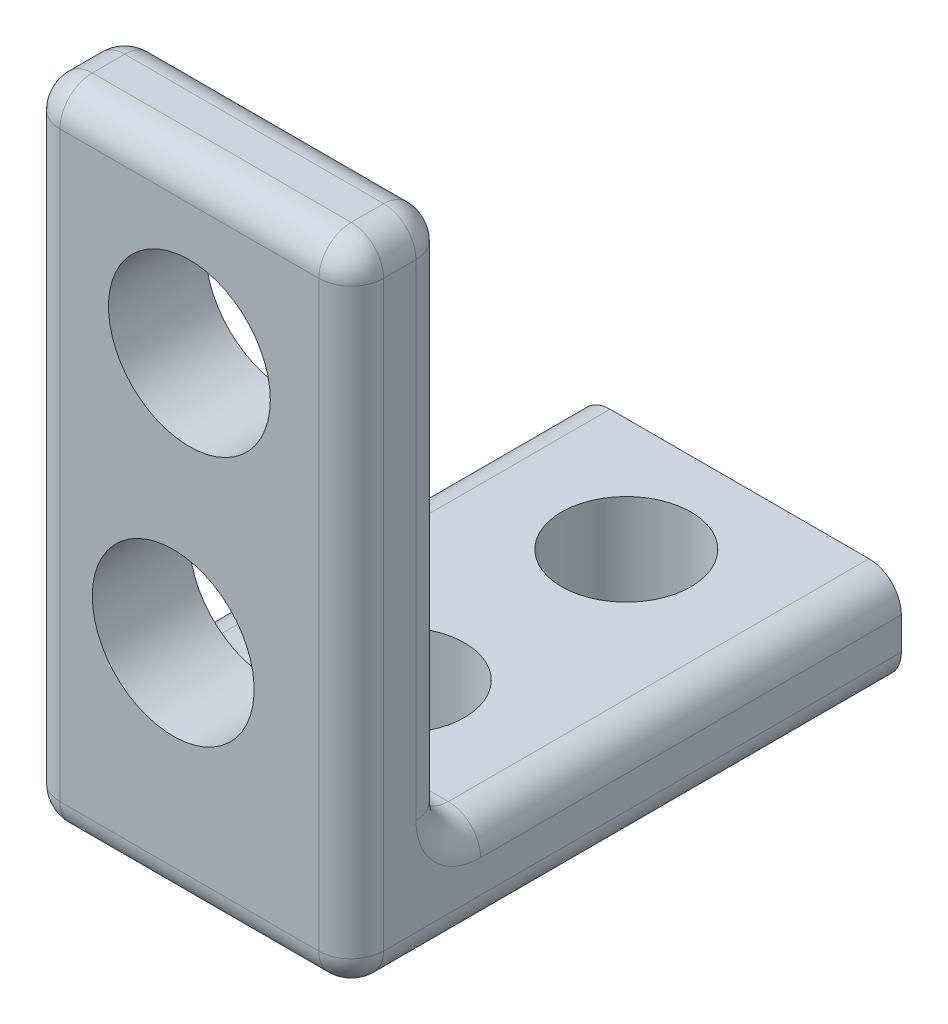
from build123d import *

# Parameters (mm, degrees)
SKETCH1_W           = 10
SKETCH1_H           = 20
BOSS_EXTRUDE1_DEPTH = 20
SKETCH2_W           = 10
SKETCH2_H           = 17
CUT_EXTRUDE1_DEPTH  = 17
SKETCH3_R           = 2.5
CUT_EXTRUDE2_DEPTH  = 21
SKETCH4_W           = 10
SKETCH4_H           = 3
CUT_EXTRUDE3_DEPTH  = 4
SKETCH5_R           = 2
CUT_EXTRUDE4_DEPTH  = 4
FILLET1_R           = 1
SKETCH6_R           = 2.5
CUT_EXTRUDE5_DEPTH  = 4


with BuildPart() as part:
    # Sketch1 → Boss-Extrude1 (new body)
    with BuildSketch(Plane(origin=(0, 0, 0), x_dir=(1, 0, 0), z_dir=(0, 1, 0))):
        with Locations((5, 10)):
            Rectangle(SKETCH1_W, SKETCH1_H)
    extrude(amount=BOSS_EXTRUDE1_DEPTH)

    # Sketch2 → Cut-Extrude1 (cut)
    with BuildSketch(Plane(origin=(0, 20, 0), x_dir=(1, 0, 0), z_dir=(0, 1, 0))):
        with Locations((5, 11.5)):
            Rectangle(SKETCH2_W, SKETCH2_H)
    extrude(amount=-CUT_EXTRUDE1_DEPTH, mode=Mode.SUBTRACT)

    # Sketch3 → Cut-Extrude2 (cut, through all)
    with BuildSketch(Plane.XY):
        with Locations((5, 15)):
            Circle(SKETCH3_R)
    extrude(amount=-CUT_EXTRUDE2_DEPTH, mode=Mode.SUBTRACT)

    # Sketch4 → Cut-Extrude3 (cut, through all)
    with BuildSketch(Plane(origin=(0, 3, 0), x_dir=(1, 0, 0), z_dir=(0, 1, 0))):
        with Locations((5, 18.5)):
            Rectangle(SKETCH4_W, SKETCH4_H)
    extrude(amount=-CUT_EXTRUDE3_DEPTH, mode=Mode.SUBTRACT)

    # Sketch5 → Cut-Extrude4 (cut, through all)
    with BuildSketch(Plane(origin=(0, 3, 0), x_dir=(1, 0, 0), z_dir=(0, 1, 0))):
        with Locations((5, 6.5)):
            Circle(SKETCH5_R)
        with Locations((5, 13.5)):
            Circle(SKETCH5_R)
    extrude(amount=-CUT_EXTRUDE4_DEPTH, mode=Mode.SUBTRACT)

    # Fillet1
    fillet1_edges = [part.edges().sort_by_distance(p)[0] for p in [
        (10, 20, -1.5),
        (0, 20, -1.5),
        (0, 11.5, -3),
        (10, 3, -10),
        (5, 3, -3),
        (10, 11.5, -3),
        (5, 20, -3),
        (0, 3, -10),
        (0, 0, -8.5),
        (10, 0, -8.5),
        (5, 0, 0),
        (10, 10, 0),
        (0, 10, 0),
        (5, 20, 0),
    ]]
    fillet(fillet1_edges, radius=FILLET1_R)

    # Sketch6 → Cut-Extrude5 (cut, through all)
    with BuildSketch(Plane(origin=(0, 0, -3), x_dir=(-1, 0, 0), z_dir=(0, 0, -1))):
        with Locations((-4.5, 7)):
            Circle(SKETCH6_R)
    extrude(amount=-CUT_EXTRUDE5_DEPTH, mode=Mode.SUBTRACT)


solid = part.part
